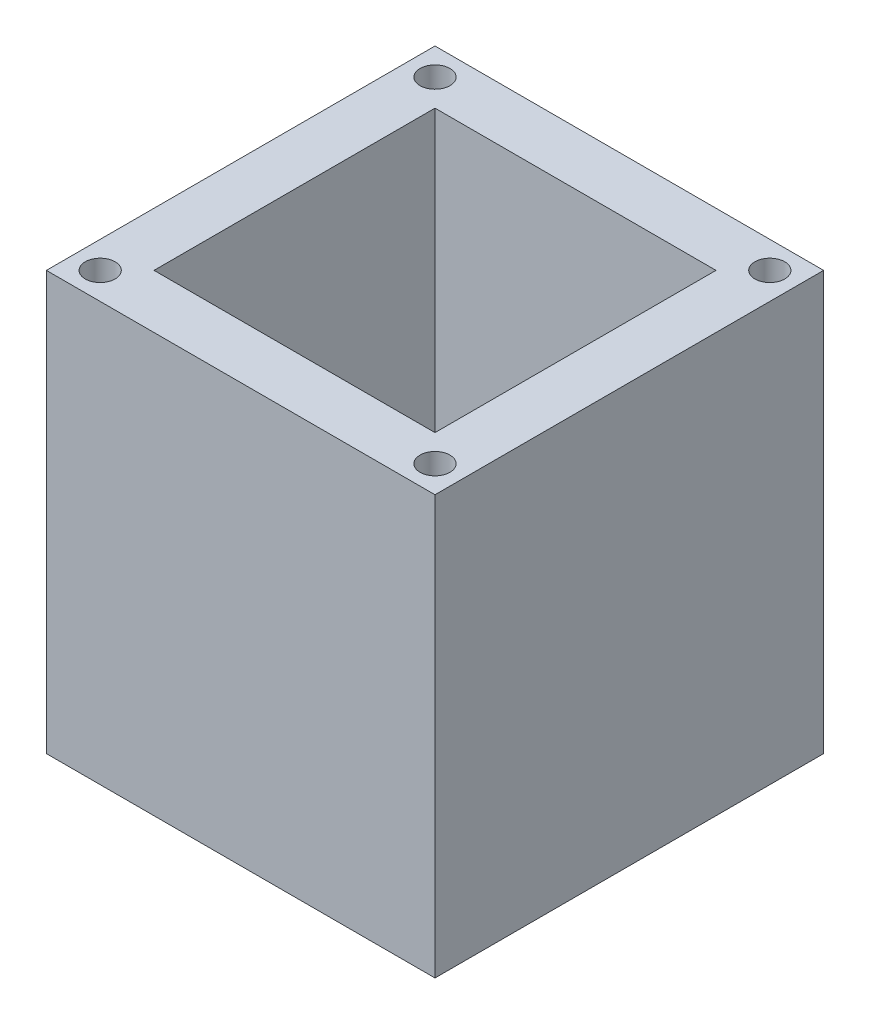
from build123d import *

# Parameters (mm, degrees)
SKETCH1_W           = 65
SKETCH1_H           = 65
BOSS_EXTRUDE1_DEPTH = 70
SKETCH2_W           = 47
SKETCH2_H           = 47
CUT_EXTRUDE1_DEPTH  = 60
SKETCH3_W           = 32
SKETCH3_H           = 32
CUT_EXTRUDE2_DEPTH  = 60
SKETCH4_R           = 2.5
CUT_EXTRUDE3_DEPTH  = 15


with BuildPart() as part:
    # Sketch1 → Boss-Extrude1 (new body)
    with BuildSketch(Plane(origin=(0, 0, 0), x_dir=(1, 0, 0), z_dir=(0, 1, 0))):
        with Locations((32.5, 32.5)):
            Rectangle(SKETCH1_W, SKETCH1_H)
    extrude(amount=BOSS_EXTRUDE1_DEPTH)

    # Sketch2 → Cut-Extrude1 (cut)
    with BuildSketch(Plane(origin=(0, 70, 0), x_dir=(1, 0, 0), z_dir=(0, 1, 0))):
        with Locations((32.5, 32.5)):
            Rectangle(SKETCH2_W, SKETCH2_H)
    extrude(amount=-CUT_EXTRUDE1_DEPTH, mode=Mode.SUBTRACT)

    # Sketch3 → Cut-Extrude2 (cut)
    with BuildSketch(Plane.XZ):
        with Locations((32.5, -32.5)):
            Rectangle(SKETCH3_W, SKETCH3_H)
    extrude(amount=-CUT_EXTRUDE2_DEPTH, mode=Mode.SUBTRACT)

    # Sketch4 → Cut-Extrude3 (cut)
    with BuildSketch(Plane(origin=(0, 70, 0), x_dir=(1, 0, 0), z_dir=(0, 1, 0))):
        with Locations((4.5, 60.5)):
            Circle(SKETCH4_R)
        with Locations((60.5, 60.5)):
            Circle(SKETCH4_R)
        with Locations((60.5, 4.5)):
            Circle(SKETCH4_R)
        with Locations((4.5, 4.5)):
            Circle(SKETCH4_R)
    extrude(amount=-CUT_EXTRUDE3_DEPTH, mode=Mode.SUBTRACT)


solid = part.part
